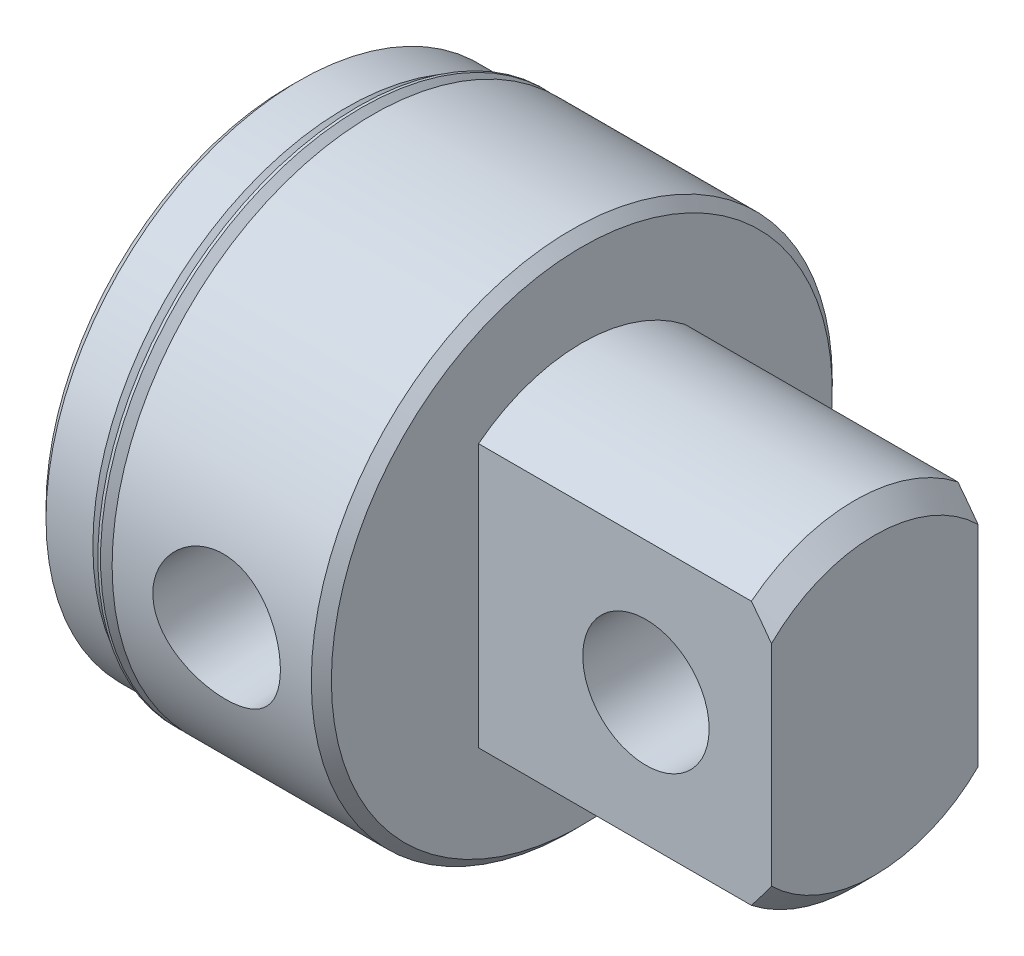
from build123d import *

# Parameters (mm, degrees)
SKETCH3_W               = 79.0702
SKETCH3_H               = 158.1404
SKETCH3_W_2             = 15.6718
SKETCH3_H_2             = 79.0702
CUT_EXTRUDE1_DEPTH      = 22.225
SKETCH6_W               = 6.35
SKETCH6_H               = 12.3063
SKETCH8_R               = 4.79425
CUT_EXTRUDE2_DEPTH      = 11.75385
CUT_EXTRUDE2_DEPTH_BACK = 11.75385


with BuildPart() as part:
    # Sketch1 → Revolve1 (revolve)
    with BuildSketch(Plane.XY):
        Polygon((0, 0), (0, 18.43405), (0.762, 19.19605), (4.318, 19.19605), (5.334, 18.18005), (6.35, 18.18005), (6.35, 19.76755), (21.463, 19.76755), (22.225, 19.00555), (22.225, 0), align=None)
    revolve(axis=Axis((22.225, 0, 0), (-1, 0, 0)))

    # Sketch2 → Revolve2 (revolve)
    with BuildSketch(Plane.XY):
        Polygon((22.225, 0), (22.225, 12.7), (42.926, 12.7), (44.45, 11.176), (44.45, 0), align=None)
    revolve(axis=Axis((44.45, 0, 0), (-1, 0, 0)))

    # Sketch3 → Cut-Extrude1 (cut)
    with BuildSketch(Plane(origin=(44.45, 0, 0), x_dir=(0, 0, -1), z_dir=(1, 0, 0))):
        Rectangle(SKETCH3_W, SKETCH3_H)
        Rectangle(SKETCH3_W_2, SKETCH3_H_2, mode=Mode.SUBTRACT)
    extrude(amount=-CUT_EXTRUDE1_DEPTH, mode=Mode.SUBTRACT)

    # Sketch4 → Cut-Revolve1 (revolve, cut)
    with BuildSketch(Plane.XY):
        Polygon((0, 0), (0, 6.7564), (20.45208, 6.7564), (24.352889359, 0), align=None)
    revolve(axis=Axis((24.352889359, 0, 0), (-1, 0, 0)), mode=Mode.SUBTRACT)

    # Sketch5 → Cut-Revolve2 (revolve, cut)
    with BuildSketch(Plane(origin=(0, 0, 0), x_dir=(1, 0, 0), z_dir=(0, 0.999847695, 0.017452406))):
        Polygon((14.2748, 0), (18.897793378, 0), (18.897793378, -12.83335), (19.114275925, -19.76755), (14.2748, -19.76755), align=None)
    revolve(axis=Axis((14.2748, -0.344991317, 19.764539306), (0, 0.017452406, -0.999847695)), mode=Mode.SUBTRACT)

    # Sketch6 → Cut-Revolve3 (revolve, cut)
    with BuildSketch(Plane.XY):
        with Locations((3.175, 6.15315)):
            Rectangle(SKETCH6_W, SKETCH6_H)
    revolve(axis=Axis((6.35, 0, 0), (-1, 0, 0)), mode=Mode.SUBTRACT)

    # Sketch7 → Revolve3 (revolve)
    with BuildSketch(Plane.XY):
        with BuildLine():
            Line((5.267509175, 19.76755), (5.267509175, 19.683381804))
            Line((5.267509175, 19.683381804), (6.216617928, 18.734273051))
            ThreePointArc((6.216617928, 18.734273051), (6.253815367, 18.64447049), (6.216617928, 18.554667928))
            Line((6.216617928, 18.554667928), (5.842, 18.18005))
            Line((5.842, 18.18005), (5.334, 18.18005))
            Line((5.334, 18.18005), (5.334, 17.92605))
            Line((5.334, 17.92605), (6.35, 17.92605))
            Line((6.35, 17.92605), (6.35, 18.888259175))
            Line((6.35, 18.888259175), (5.470709175, 19.76755))
            Line((5.470709175, 19.76755), (5.267509175, 19.76755))
        make_face()
    revolve(axis=Axis((6.35, 0, 0), (-1, 0, 0)))

    # Sketch8 → Cut-Extrude2 (cut, two sides)
    with BuildSketch(Plane.XY) as cut_extrude2_sk:
        with Locations((34.925, 0)):
            Circle(SKETCH8_R)
    extrude(amount=CUT_EXTRUDE2_DEPTH, mode=Mode.SUBTRACT)
    extrude(cut_extrude2_sk.sketch, amount=-CUT_EXTRUDE2_DEPTH_BACK, mode=Mode.SUBTRACT)


solid = part.part
